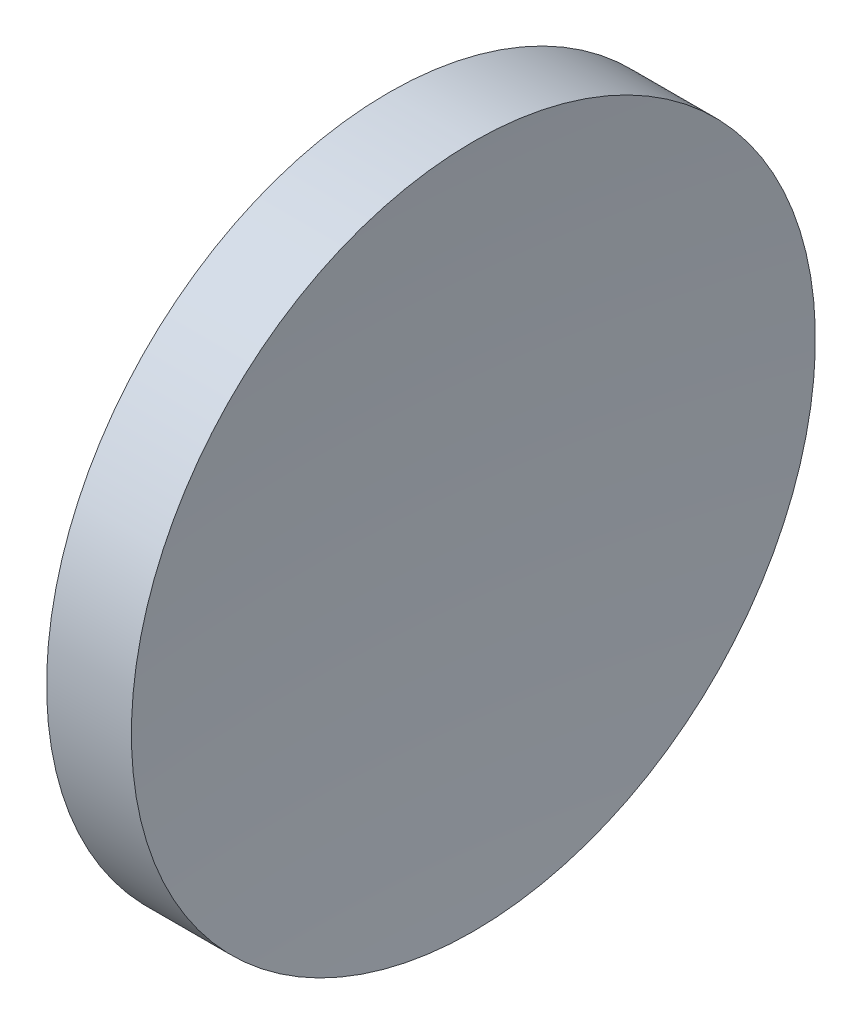
from build123d import *


with BuildPart() as part:
    # 草图1 → 旋转1 (revolve)
    with BuildSketch(Plane.XY, mode=Mode.PRIVATE) as revolve_1_sk:
        with BuildLine():
            Line((97.090443968, 52.178082298), (95.090443968, 52.178082298))
            ThreePointArc((95.090443968, 52.178082298), (94.946887654, 58.534563214), (94.516511445, 64.878082298))
            Line((94.516511445, 64.878082298), (96.090443968, 64.878082298))
            Line((96.090443968, 64.878082298), (97.664376492, 64.878082298))
            ThreePointArc((97.664376492, 64.878082298), (97.234000282, 58.534563214), (97.090443968, 52.178082298))
        make_face()
    revolve(revolve_1_sk.sketch.rotate(Axis((89.858656454, 52.178082298, 0), (1, 0, 0)), 180), axis=Axis((89.858656454, 52.178082298, 0), (1, 0, 0)))  # turned: the seam where the file's is


solid = part.part
